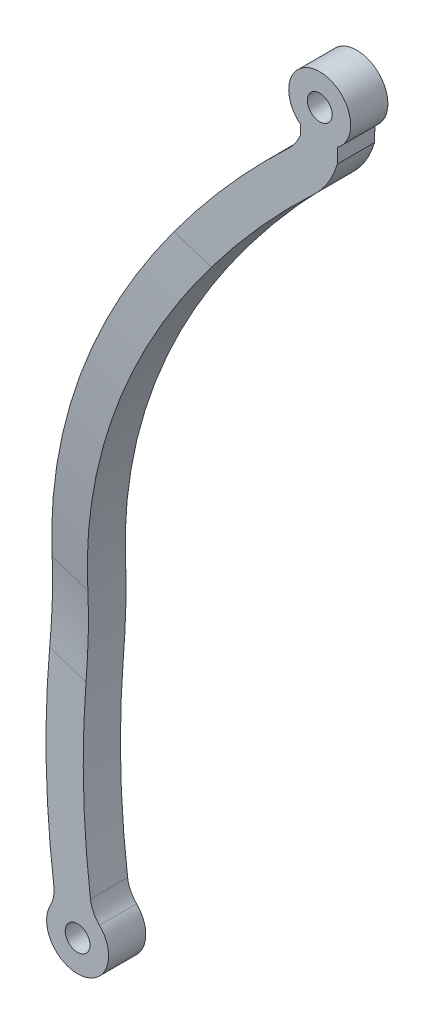
from build123d import *

# Parameters (mm, degrees)
SKETCH1_R           = 4
BOSS_EXTRUDE1_DEPTH = 30
FILLET1_R           = 10
CUT_EXTRUDE1_DEPTH  = 50


with BuildPart() as part:
    # Sketch1 → Boss-Extrude1 (new body)
    with BuildSketch(Plane.XY):
        with BuildLine():
            Line((138.503487168, 271.253231947), (138.386569071, 266.427133764))
            ThreePointArc((138.386569071, 266.427133764), (135.506043856, 259.89792897), (131.004003349, 254.360820334))
            ThreePointArc((131.004003349, 254.360820334), (55.014402731, 137.639339628), (41.273132032, -0.959004301))
            ThreePointArc((41.273132032, -0.959004301), (38.103150753, -19.665773564), (29.413949453, -2.798948778))
            ThreePointArc((29.413949453, -2.798948778), (43.666158034, 141.541101292), (122.784429578, 263.103737869))
            ThreePointArc((122.784429578, 263.103737869), (124.910300495, 265.601515317), (126.433420754, 268.506394661))
            Line((126.433420754, 268.506394661), (126.507007076, 271.543861264))
            ThreePointArc((126.507007076, 271.543861264), (132.941191098, 289.393266743), (138.503487168, 271.253231947))
        make_face()
        with Locations((36.57, -9.784)):
            Circle(SKETCH1_R, mode=Mode.SUBTRACT)
        with Locations((132.699, 279.3962)):
            Circle(SKETCH1_R, mode=Mode.SUBTRACT)
    extrude(amount=-BOSS_EXTRUDE1_DEPTH)

    # Fillet1
    fillet1_edges = [part.edges().sort_by_distance(p)[0] for p in [
        (29.413949453, -2.798948778, -15),
        (41.273132032, -0.959004301, -15),
    ]]
    fillet(fillet1_edges, radius=FILLET1_R)

    # Sketch2 → Cut-Extrude1 (cut, symmetric)
    with BuildSketch(Plane(origin=(35.859794138, -11.920477788, 0), x_dir=(0, 0, -1), z_dir=(0.9489432648360645, -0.31544679443968165, 0))):
        with BuildLine():
            Line((18, -41.651017654), (18, 72.25142837))
            ThreePointArc((18, 72.25142837), (17.213593845, 86.688920515), (14.863680684, 100.955578225))
            ThreePointArc((14.863680684, 100.955578225), (3.726945122, 168.568287043), (0, 236.990616386))
            Line((0, 236.990616386), (-79.914214629, -10.518807221))
            Line((-79.914214629, -10.518807221), (18, -41.651017654))
        make_face()
        with BuildLine():
            ThreePointArc((12, 236.990616386), (15.655931666, 169.871851405), (26.580467348, 103.547278514))
            ThreePointArc((26.580467348, 103.547278514), (29.14258039, 87.992484876), (30, 72.25142837))
            Line((30, 72.25142837), (155.717662302, 285.460245478))
            Line((155.717662302, 285.460245478), (12, 328.230650316))
            Line((12, 328.230650316), (12, 236.990616386))
        make_face()
    extrude(amount=CUT_EXTRUDE1_DEPTH, both=True, mode=Mode.SUBTRACT)


solid = part.part
